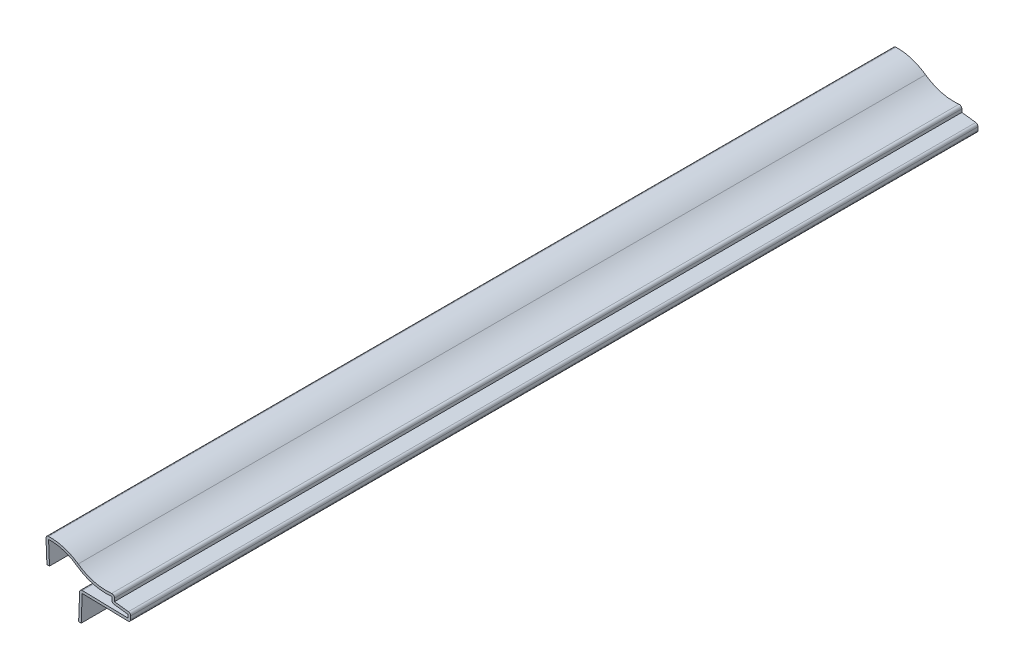
from build123d import *

# Parameters (mm, degrees)
EXTRUDE_THIN1_DEPTH = 333.375
FILLET1_R           = 1.016


with BuildPart() as part:
    # Sketch1 → Extrude-Thin1 (new body)
    with BuildSketch(Plane.XY):
        with BuildLine():
            Line((0, 0), (-0.396875, 9.921875))
            ThreePointArc((-0.396875, 9.921875), (6.266318546, 9.299504076), (12.303125, 6.411172093))
            ThreePointArc((12.303125, 6.411172093), (19.115525264, 3.32587731), (26.590625, 3.100654804))
            Line((26.590625, 3.100654804), (26.590625, 0.719404804))
            Line((26.590625, 0.719404804), (32.940625, -0.074345196))
            Line((32.940625, -0.074345196), (32.940625, -3.249345196))
            Line((32.940625, -3.249345196), (13.890625, -2.852470196))
            Line((13.890625, -2.852470196), (13.49375, -13.165191036))
            Line((13.49375, -13.165191036), (12.478501524, -13.126120189))
            Line((12.478501524, -13.126120189), (12.913764372, -1.815898471))
            Line((12.913764372, -1.815898471), (31.924625, -2.211958067))
            Line((31.924625, -2.211958067), (31.924625, -0.97125193))
            Line((31.924625, -0.97125193), (25.574625, -0.17750193))
            Line((25.574625, -0.17750193), (25.574625, 1.934694963))
            ThreePointArc((25.574625, 1.934694963), (18.305318895, 2.479849648), (11.710458333, 5.585943505))
            ThreePointArc((11.710458333, 5.585943505), (6.462301295, 8.184427992), (0.658241432, 8.964276082))
            Line((0.658241432, 8.964276082), (1.015188174, 0.040607527))
            Line((1.015188174, 0.040607527), (0, 0))
        make_face()
    extrude(amount=-EXTRUDE_THIN1_DEPTH)

    # Fillet1
    fillet1_edges = [part.edges().sort_by_distance(p)[0] for p in [
        (12.913764372, -1.815898471, -166.6875),
        (25.574625, -0.17750193, -166.6875),
        (-0.396875, 9.921875, -166.6875),
        (26.590625, 3.100654804, -166.6875),
        (32.940625, -0.074345196, -166.6875),
        (32.940625, -3.249345196, -166.6875),
    ]]
    fillet(fillet1_edges, radius=FILLET1_R)


solid = part.part
